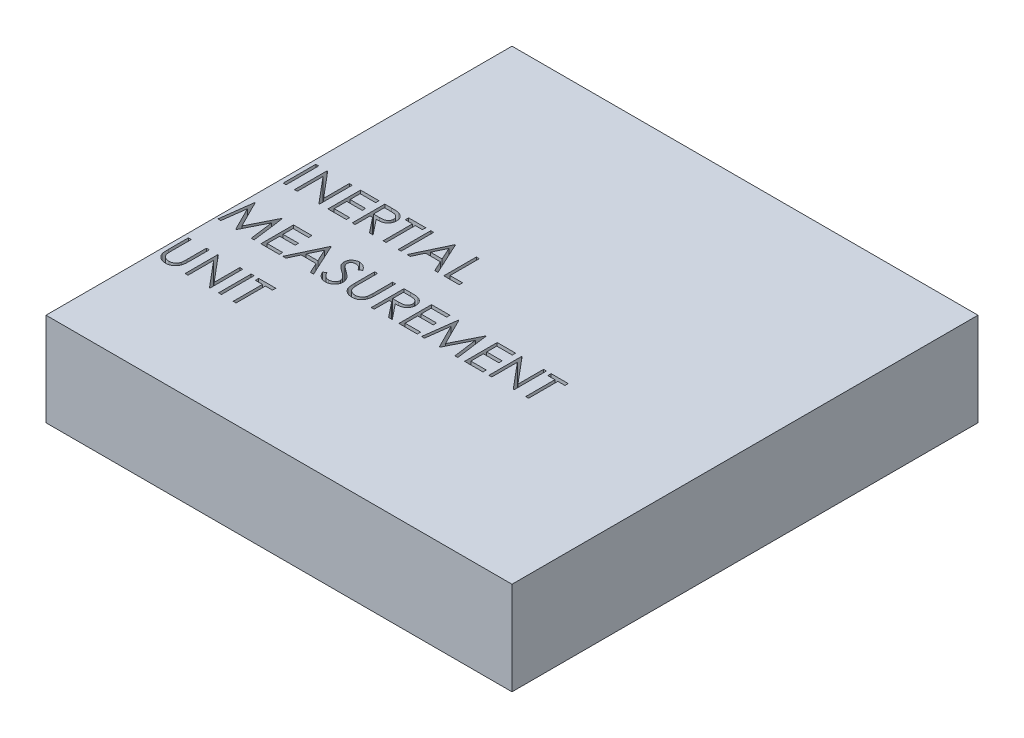
from build123d import *

# Parameters (mm, degrees)
SKETCH1_W           = 50
SKETCH1_H           = 50
BOSS_EXTRUDE1_DEPTH = 10
SKETCH2_W           = 0.314102564
SKETCH2_H           = 3.5
SKETCH2_W_2         = 0.314102565
CUT_EXTRUDE1_DEPTH  = 11


with BuildPart() as part:
    # Sketch1 → Boss-Extrude1 (new body)
    with BuildSketch(Plane(origin=(0, 0, 0), x_dir=(1, 0, 0), z_dir=(0, 1, 0))):
        with Locations((25, 25)):
            Rectangle(SKETCH1_W, SKETCH1_H)
    extrude(amount=BOSS_EXTRUDE1_DEPTH)

    # Sketch2 → Cut-Extrude1 (cut, through all)
    with BuildSketch(Plane(origin=(0, 10, 0), x_dir=(1, 0, 0), z_dir=(0, 1, 0))):
        with Locations((0.605769231, 26.75)):
            Rectangle(SKETCH2_W, SKETCH2_H)
        Polygon((1.66025641, 25), (1.66025641, 28.5), (1.726161859, 28.5), (4.038461538, 25.745292468), (4.038461538, 28.5), (4.352564103, 28.5), (4.352564103, 25), (4.281049679, 25), (1.974358974, 27.748397436), (1.974358974, 25), align=None)
        Polygon((5.25, 28.5), (7.224358974, 28.5), (7.224358974, 28.141025641), (5.564102564, 28.141025641), (5.564102564, 27.064102564), (7.224358974, 27.064102564), (7.224358974, 26.705128205), (5.564102564, 26.705128205), (5.564102564, 25.358974359), (7.224358974, 25.358974359), (7.224358974, 25), (5.25, 25), align=None)
        with BuildLine():
            Line((7.852564103, 28.5), (8.552984776, 28.5))
            add(Edge.make_bspline(
                [(8.552984776, 28.5), (8.599725904, 28.499844414), (8.689474049, 28.499545672), (8.818047319, 28.497879909), (8.934874416, 28.493105553), (9.039894255, 28.48899697), (9.13310491, 28.481505028), (9.214792201, 28.474344381), (9.284579898, 28.46497072), (9.32682575, 28.456265297), (9.345953526, 28.452323718)],
                knots=[0, 0, 0, 0, 0.000140226, 0.00026925, 0.000385712, 0.000490995, 0.000584507, 0.000666202, 0.000736998, 0.000795574, 0.000795574, 0.000795574, 0.000795574], degree=3))
            add(Edge.make_bspline(
                [(9.345953526, 28.452323718), (9.37156015, 28.445996953), (9.422227139, 28.433478389), (9.495177205, 28.407018788), (9.564691529, 28.376399163), (9.630481354, 28.340435443), (9.692217145, 28.298860663), (9.750535456, 28.252392541), (9.805700919, 28.201285335), (9.855482549, 28.144250494), (9.902421601, 28.084413984), (9.942010227, 28.019710227), (9.976136707, 27.9520487), (10.003307224, 27.880741282), (10.025185197, 27.80647951), (10.040611437, 27.728590713), (10.049862625, 27.647429738), (10.05080448, 27.59207183), (10.051282051, 27.564002404)],
                knots=[0, 0, 0, 0, 7.9081e-05, 0.000156475, 0.000232432, 0.000306798, 0.00038108, 0.000455429, 0.000530331, 0.000606314, 0.000682321, 0.000758201, 0.000833453, 0.000909362, 0.000986794, 0.001065445, 0.001147284, 0.001231465, 0.001231465, 0.001231465, 0.001231465], degree=3))
            add(Edge.make_bspline(
                [(10.051282051, 27.564002404), (10.049813053, 27.517367299), (10.046946657, 27.426370131), (10.020221554, 27.29430925), (9.976445034, 27.171119935), (9.916121745, 27.056957297), (9.839302269, 26.954046652), (9.746977478, 26.863656197), (9.639095867, 26.788016284), (9.538666551, 26.735563479), (9.449952351, 26.701970571), (9.376919038, 26.678334212), (9.297252061, 26.660072247), (9.211714726, 26.643712115), (9.119951071, 26.63136042), (9.022181031, 26.622313826), (8.91833488, 26.616659777), (8.84699581, 26.615817772), (8.810296474, 26.615384615)],
                knots=[0, 0, 0, 0, 0.000139777, 0.000272741, 0.000402249, 0.000530843, 0.000658588, 0.000786009, 0.000916741, 0.001052522, 0.001124656, 0.001201155, 0.001282612, 0.001369656, 0.001462366, 0.001560247, 0.001664165, 0.001774261, 0.001774261, 0.001774261, 0.001774261], degree=3))
            Line((8.810296474, 26.615384615), (10.096153846, 25))
            Line((10.096153846, 25), (9.707732372, 25))
            Line((9.707732372, 25), (8.421875, 26.615384615))
            Line((8.421875, 26.615384615), (8.166666667, 26.615384615))
            Line((8.166666667, 26.615384615), (8.166666667, 25))
            Line((8.166666667, 25), (7.852564103, 25))
            Line((7.852564103, 25), (7.852564103, 28.5))
        make_face()
        with BuildLine():
            Line((8.166666667, 28.141025641), (8.166666667, 26.974358974))
            Line((8.166666667, 26.974358974), (8.807491987, 26.969451122))
            add(Edge.make_bspline(
                [(8.807491987, 26.969451122), (8.837412026, 26.969437885), (8.895405583, 26.969412229), (8.979306248, 26.973406005), (9.05742636, 26.977949323), (9.129467112, 26.984898669), (9.195460687, 26.99385474), (9.2553741, 27.005057725), (9.309305152, 27.018109787), (9.372203691, 27.038311413), (9.442440222, 27.070317431), (9.518771682, 27.11688293), (9.58377402, 27.175452049), (9.638691882, 27.242425505), (9.682821314, 27.316061754), (9.713933368, 27.395478123), (9.73367581, 27.478669721), (9.736004356, 27.535847829), (9.737179487, 27.564703526)],
                knots=[0, 0, 0, 0, 8.9746e-05, 0.000173954, 0.000251933, 0.000324488, 0.000391021, 0.000451663, 0.000507268, 0.000557378, 0.000649639, 0.000738152, 0.000824558, 0.000910739, 0.000997194, 0.001080909, 0.00116578, 0.001252248, 0.001252248, 0.001252248, 0.001252248], degree=3))
            add(Edge.make_bspline(
                [(9.737179487, 27.564703526), (9.735977366, 27.592850099), (9.733595201, 27.648626338), (9.714146432, 27.730282248), (9.681257051, 27.807349198), (9.636934813, 27.879513683), (9.582935658, 27.945019419), (9.519617845, 28.001066572), (9.44871265, 28.047316037), (9.382441452, 28.076870418), (9.323207239, 28.094990271), (9.271777579, 28.107741435), (9.213666102, 28.117985904), (9.148590643, 28.126193964), (9.076829012, 28.133248909), (8.998018361, 28.138000687), (8.912681581, 28.140814551), (8.85353465, 28.14095364), (8.822916667, 28.141025641)],
                knots=[0, 0, 0, 0, 8.4371e-05, 0.000167192, 0.000250141, 0.000334794, 0.000420435, 0.000503871, 0.000587493, 0.000673488, 0.0007205, 0.000773215, 0.000832351, 0.0008974, 0.000969955, 0.001048634, 0.001134217, 0.001226067, 0.001226067, 0.001226067, 0.001226067], degree=3))
            Line((8.822916667, 28.141025641), (8.166666667, 28.141025641))
        make_face(mode=Mode.SUBTRACT)
        Polygon((10.41025641, 28.141025641), (10.41025641, 28.5), (12.25, 28.5), (12.25, 28.141025641), (11.487179487, 28.141025641), (11.487179487, 25), (11.173076923, 25), (11.173076923, 28.141025641), align=None)
        with Locations((12.94551282, 26.75)):
            Rectangle(SKETCH2_W_2, SKETCH2_H)
        Polygon((15.435897436, 28.5), (17.051282051, 25), (16.709835737, 25), (16.192407853, 26.121794872), (14.605769231, 26.121794872), (14.07431891, 25), (13.730769231, 25), (15.391025641, 28.5), align=None)
        Polygon((15.409955929, 27.817107372), (14.776842949, 26.480769231), (16.026943109, 26.480769231), align=None, mode=Mode.SUBTRACT)
        Polygon((17.679487179, 28.5), (17.993589744, 28.5), (17.993589744, 25.358974359), (19.33974359, 25.358974359), (19.33974359, 25), (17.679487179, 25), align=None)
        Polygon((0.269230769, 18.166666667), (0.731270032, 21.666666667), (0.776141827, 21.666666667), (2.221153846, 18.794871795), (3.661959135, 21.666666667), (3.706830929, 21.666666667), (4.173076923, 18.166666667), (3.858974359, 18.166666667), (3.522435897, 20.682992788), (2.259715545, 18.166666667), (2.188201122, 18.166666667), (0.919871795, 20.690705128), (0.585436699, 18.166666667), align=None)
        Polygon((4.891025641, 21.666666667), (6.865384615, 21.666666667), (6.865384615, 21.307692308), (5.205128205, 21.307692308), (5.205128205, 20.230769231), (6.865384615, 20.230769231), (6.865384615, 19.871794872), (5.205128205, 19.871794872), (5.205128205, 18.525641026), (6.865384615, 18.525641026), (6.865384615, 18.166666667), (4.891025641, 18.166666667), align=None)
        Polygon((8.929487179, 21.666666667), (10.544871795, 18.166666667), (10.203425481, 18.166666667), (9.685997596, 19.288461538), (8.099358974, 19.288461538), (7.567908654, 18.166666667), (7.224358974, 18.166666667), (8.884615385, 21.666666667), align=None)
        Polygon((8.903545673, 20.983774038), (8.270432692, 19.647435897), (9.520532853, 19.647435897), align=None, mode=Mode.SUBTRACT)
        with BuildLine():
            Line((10.814102564, 18.841846955), (11.109975962, 19.019230769))
            add(Edge.make_bspline(
                [(11.109975962, 19.019230769), (11.137494199, 18.973166384), (11.190218079, 18.8849088), (11.278169439, 18.76565076), (11.36930235, 18.664288603), (11.464291683, 18.581411996), (11.562557631, 18.516163109), (11.664741685, 18.469960877), (11.770499496, 18.441144902), (11.842473317, 18.437644815), (11.878405449, 18.435897436)],
                knots=[0, 0, 0, 0, 0.000160901, 0.00030828, 0.000443778, 0.00056903, 0.000685513, 0.000796284, 0.00090427, 0.001011928, 0.001011928, 0.001011928, 0.001011928], degree=3))
            add(Edge.make_bspline(
                [(11.878405449, 18.435897436), (11.909092309, 18.436752108), (11.969929082, 18.438446499), (12.059491325, 18.454727301), (12.146473128, 18.47973943), (12.229081765, 18.515560361), (12.30617738, 18.558898847), (12.373784075, 18.611245024), (12.432230188, 18.66985123), (12.480039303, 18.735233885), (12.516719338, 18.805551033), (12.544911407, 18.877726985), (12.56055648, 18.952895553), (12.562913234, 19.003506016), (12.564102564, 19.029046474)],
                knots=[0, 0, 0, 0, 9.1978e-05, 0.000182347, 0.000272202, 0.000362975, 0.000451852, 0.000536835, 0.000618639, 0.000699414, 0.000778765, 0.000855983, 0.0009312, 0.001007828, 0.001007828, 0.001007828, 0.001007828], degree=3))
            add(Edge.make_bspline(
                [(12.564102564, 19.029046474), (12.562628253, 19.058187324), (12.559631195, 19.117426413), (12.534299715, 19.204826066), (12.494450468, 19.291318636), (12.457687825, 19.344819902), (12.438601763, 19.372596154)],
                knots=[0, 0, 0, 0, 8.7281e-05, 0.000177429, 0.000270909, 0.000371844, 0.000371844, 0.000371844, 0.000371844], degree=3))
            add(Edge.make_bspline(
                [(12.438601763, 19.372596154), (12.422931149, 19.392642977), (12.390032654, 19.434728776), (12.333475142, 19.497374011), (12.267109027, 19.56199243), (12.193205473, 19.631051487), (12.109072384, 19.701339284), (12.017344869, 19.776207562), (11.91568101, 19.852809139), (11.844381514, 19.904181705), (11.807592147, 19.930689103)],
                knots=[0, 0, 0, 0, 7.6319e-05, 0.000160223, 0.000252933, 0.000354147, 0.000463581, 0.000581729, 0.000709336, 0.000845369, 0.000845369, 0.000845369, 0.000845369], degree=3))
            add(Edge.make_bspline(
                [(11.807592147, 19.930689103), (11.770768151, 19.95691769), (11.700363475, 20.007064752), (11.601904892, 20.081489036), (11.513860429, 20.149532906), (11.436621413, 20.211836918), (11.370221816, 20.268409523), (11.314138405, 20.318707462), (11.269799848, 20.364091023), (11.245144267, 20.393532365), (11.234074519, 20.406750801)],
                knots=[0, 0, 0, 0, 0.000135623, 0.000259301, 0.000370234, 0.000469439, 0.00055697, 0.000631911, 0.000695377, 0.00074709, 0.00074709, 0.00074709, 0.00074709], degree=3))
            add(Edge.make_bspline(
                [(11.234074519, 20.406750801), (11.218601974, 20.427351838), (11.188173137, 20.467866542), (11.148007132, 20.5311914), (11.113867969, 20.596014665), (11.087105637, 20.66251053), (11.064569418, 20.729745459), (11.049411487, 20.798596704), (11.03992009, 20.868755323), (11.038948104, 20.915968823), (11.038461538, 20.939603365)],
                knots=[0, 0, 0, 0, 7.727e-05, 0.000151962, 0.000224716, 0.000296717, 0.00036678, 0.0004372, 0.000507902, 0.000578771, 0.000578771, 0.000578771, 0.000578771], degree=3))
            add(Edge.make_bspline(
                [(11.038461538, 20.939603365), (11.039766747, 20.97663314), (11.042349268, 21.049901204), (11.064189785, 21.156932034), (11.098662678, 21.259118451), (11.146957566, 21.355448785), (11.209214919, 21.443414766), (11.281260894, 21.524028253), (11.36707238, 21.591796835), (11.461225003, 21.651008894), (11.564281375, 21.697354819), (11.672272279, 21.732315799), (11.785369351, 21.752125057), (11.861972485, 21.754967822), (11.900841346, 21.756410256)],
                knots=[0, 0, 0, 0, 0.000110999, 0.000219625, 0.000326272, 0.00043382, 0.000541574, 0.000648775, 0.000756959, 0.000868438, 0.000981703, 0.00109501, 0.001208203, 0.0013248, 0.0013248, 0.0013248, 0.0013248], degree=3))
            add(Edge.make_bspline(
                [(11.900841346, 21.756410256), (11.942085446, 21.754987705), (12.024106798, 21.752158704), (12.144756014, 21.727561172), (12.26091673, 21.686860501), (12.354359995, 21.640671843), (12.427492756, 21.594540427), (12.483265489, 21.552520603), (12.53978294, 21.504145494), (12.597500995, 21.449286248), (12.655441654, 21.387439497), (12.714465106, 21.319028808), (12.774709375, 21.244472252), (12.813465235, 21.191247751), (12.833333333, 21.16396234)],
                knots=[0, 0, 0, 0, 0.000123638, 0.000245877, 0.000367608, 0.000492088, 0.000557638, 0.000626769, 0.000701372, 0.00078072, 0.000865532, 0.000955497, 0.001051745, 0.001152989, 0.001152989, 0.001152989, 0.001152989], degree=3))
            Line((12.833333333, 21.16396234), (12.549379006, 20.948717949))
            add(Edge.make_bspline(
                [(12.549379006, 20.948717949), (12.532233074, 20.970806639), (12.499214017, 21.013344292), (12.44908453, 21.072915608), (12.401835882, 21.127332088), (12.355285482, 21.174597216), (12.311891851, 21.217299349), (12.269774809, 21.253859106), (12.229540457, 21.284634701), (12.178823547, 21.317478261), (12.115105828, 21.350034765), (12.035121292, 21.377583843), (11.951535017, 21.394138905), (11.894605386, 21.396327792), (11.865785256, 21.397435897)],
                knots=[0, 0, 0, 0, 8.3877e-05, 0.000161528, 0.000233552, 0.000299993, 0.000360485, 0.000416152, 0.000467195, 0.000512312, 0.000597287, 0.000681099, 0.000765389, 0.000851809, 0.000851809, 0.000851809, 0.000851809], degree=3))
            add(Edge.make_bspline(
                [(11.865785256, 21.397435897), (11.829628734, 21.396224197), (11.759904287, 21.393887548), (11.66091405, 21.368367563), (11.571820125, 21.328185703), (11.49526756, 21.271870725), (11.431530583, 21.205149732), (11.385425125, 21.128370877), (11.35767496, 21.043588474), (11.35428868, 20.984446818), (11.352564103, 20.954326923)],
                knots=[0, 0, 0, 0, 0.000108248, 0.000208746, 0.00030443, 0.000399793, 0.000492054, 0.00057947, 0.000666386, 0.000756591, 0.000756591, 0.000756591, 0.000756591], degree=3))
            add(Edge.make_bspline(
                [(11.352564103, 20.954326923), (11.352957229, 20.935575445), (11.353744125, 20.898041825), (11.364718923, 20.842590403), (11.378818252, 20.787279064), (11.401160884, 20.732356481), (11.432006187, 20.676862122), (11.472511363, 20.619840384), (11.523524675, 20.560788676), (11.562601688, 20.522381302), (11.583233173, 20.502103365)],
                knots=[0, 0, 0, 0, 5.616e-05, 0.000112411, 0.000169046, 0.000227244, 0.000289691, 0.000359134, 0.000436702, 0.000523463, 0.000523463, 0.000523463, 0.000523463], degree=3))
            add(Edge.make_bspline(
                [(11.583233173, 20.502103365), (11.590894545, 20.49526634), (11.609096213, 20.479023131), (11.642372138, 20.452430851), (11.686314937, 20.419628078), (11.739777138, 20.379040762), (11.803744499, 20.3319593), (11.878224056, 20.278985688), (11.962385588, 20.218400229), (12.022107504, 20.176042688), (12.053685897, 20.153645833)],
                knots=[0, 0, 0, 0, 3.0802e-05, 7.3177e-05, 0.000127725, 0.000195314, 0.000274544, 0.000365991, 0.000469501, 0.000585644, 0.000585644, 0.000585644, 0.000585644], degree=3))
            add(Edge.make_bspline(
                [(12.053685897, 20.153645833), (12.091671811, 20.126004474), (12.165226267, 20.072480812), (12.269883847, 19.992065132), (12.364777655, 19.913417363), (12.450240859, 19.837039756), (12.527117767, 19.763511663), (12.594555488, 19.691948483), (12.653241168, 19.62286291), (12.716420387, 19.534290335), (12.780978206, 19.42550925), (12.836419714, 19.292231012), (12.871378061, 19.158434691), (12.875949576, 19.068507855), (12.878205128, 19.024138622)],
                knots=[0, 0, 0, 0, 0.000140932, 0.000272896, 0.000395881, 0.000510584, 0.000616697, 0.000714904, 0.000805482, 0.000888372, 0.001041088, 0.001183793, 0.001320341, 0.001453327, 0.001453327, 0.001453327, 0.001453327], degree=3))
            add(Edge.make_bspline(
                [(12.878205128, 19.024138622), (12.87754799, 18.992760257), (12.876246475, 18.930612873), (12.861285561, 18.839357796), (12.839365896, 18.750726927), (12.806328662, 18.665815814), (12.766005504, 18.583071051), (12.714839256, 18.504663151), (12.655531571, 18.428856752), (12.587497806, 18.357673261), (12.513051904, 18.292327065), (12.434368209, 18.234198004), (12.351317936, 18.18572968), (12.26435162, 18.146178838), (12.173449283, 18.115245321), (12.078641499, 18.092832452), (11.979771988, 18.079076741), (11.912571506, 18.077648979), (11.878405449, 18.076923077)],
                knots=[0, 0, 0, 0, 9.4044e-05, 0.000186263, 0.000276729, 0.000367488, 0.000459046, 0.000552398, 0.000647774, 0.000747454, 0.000847311, 0.000944634, 0.001040472, 0.001135227, 0.001230788, 0.001328063, 0.00142712, 0.00152957, 0.00152957, 0.00152957, 0.00152957], degree=3))
            add(Edge.make_bspline(
                [(11.878405449, 18.076923077), (11.851970106, 18.077434259), (11.799432346, 18.078450184), (11.721722864, 18.087431464), (11.645583275, 18.100138568), (11.571968993, 18.120312638), (11.499931581, 18.144789615), (11.429784346, 18.174927948), (11.361493293, 18.211045149), (11.29467571, 18.252340174), (11.229501535, 18.300397918), (11.166582067, 18.356371415), (11.103852882, 18.41871692), (11.043165485, 18.489127483), (10.983292341, 18.566465566), (10.925413931, 18.651454749), (10.868332214, 18.743632103), (10.832516746, 18.808497189), (10.814102564, 18.841846955)],
                knots=[0, 0, 0, 0, 7.9276e-05, 0.000157554, 0.000234438, 0.000310629, 0.000386236, 0.000462555, 0.000539392, 0.000617798, 0.000698008, 0.000781971, 0.000870217, 0.00096315, 0.001060616, 0.001163492, 0.001271478, 0.00138575, 0.00138575, 0.00138575, 0.00138575], degree=3))
        make_face()
        with BuildLine():
            Line((13.596153846, 21.666666667), (13.91025641, 21.666666667))
            Line((13.91025641, 21.666666667), (13.91025641, 19.569611378))
            add(Edge.make_bspline(
                [(13.91025641, 19.569611378), (13.910209666, 19.539930642), (13.910120962, 19.483606332), (13.910713475, 19.403438031), (13.912372844, 19.332165572), (13.913419003, 19.269514224), (13.915746337, 19.215771477), (13.917644384, 19.170646166), (13.920084941, 19.134351964), (13.923018058, 19.113171038), (13.924278846, 19.104066506)],
                knots=[0, 0, 0, 0, 8.9042e-05, 0.000168973, 0.000240502, 0.000302917, 0.000356945, 0.000401866, 0.000438432, 0.000465999, 0.000465999, 0.000465999, 0.000465999], degree=3))
            add(Edge.make_bspline(
                [(13.924278846, 19.104066506), (13.929456305, 19.071219743), (13.939519491, 19.007377014), (13.965165869, 18.916468732), (14.00098337, 18.834537274), (14.043426413, 18.759025983), (14.099359024, 18.692036623), (14.166362559, 18.63032497), (14.247540328, 18.576353165), (14.337800934, 18.527002353), (14.435086171, 18.487337271), (14.534497437, 18.457343907), (14.634540417, 18.439065007), (14.701516582, 18.436948468), (14.734775641, 18.435897436)],
                knots=[0, 0, 0, 0, 9.971e-05, 0.000193801, 0.000282365, 0.000367504, 0.000452699, 0.000543015, 0.000639862, 0.000744331, 0.000851226, 0.000954377, 0.001055468, 0.001155185, 0.001155185, 0.001155185, 0.001155185], degree=3))
            add(Edge.make_bspline(
                [(14.734775641, 18.435897436), (14.763329381, 18.436971286), (14.820271943, 18.439112784), (14.904878374, 18.452374215), (14.987278483, 18.476274781), (15.067879163, 18.50711454), (15.143430147, 18.547862131), (15.213973589, 18.59493297), (15.276937523, 18.650143846), (15.334395521, 18.711244191), (15.384430457, 18.780183991), (15.427801599, 18.855462129), (15.463327528, 18.938211476), (15.480871053, 18.996365898), (15.489883814, 19.026241987)],
                knots=[0, 0, 0, 0, 8.5678e-05, 0.00017086, 0.000256092, 0.000342674, 0.000429242, 0.000513055, 0.000596556, 0.000679898, 0.000764179, 0.00085149, 0.000940054, 0.001033621, 0.001033621, 0.001033621, 0.001033621], degree=3))
            add(Edge.make_bspline(
                [(15.489883814, 19.026241987), (15.492883939, 19.038590562), (15.499569428, 19.066108162), (15.505816473, 19.112629452), (15.512322998, 19.167518816), (15.516837568, 19.231170629), (15.521238788, 19.303371602), (15.523871861, 19.384497859), (15.525088894, 19.47425482), (15.525451574, 19.536891982), (15.525641026, 19.569611378)],
                knots=[0, 0, 0, 0, 3.81e-05, 8.4902e-05, 0.000140649, 0.000203941, 0.000276279, 0.000357657, 0.000447412, 0.000545571, 0.000545571, 0.000545571, 0.000545571], degree=3))
            Line((15.525641026, 19.569611378), (15.525641026, 21.666666667))
            Line((15.525641026, 21.666666667), (15.83974359, 21.666666667))
            Line((15.83974359, 21.666666667), (15.83974359, 19.552784455))
            add(Edge.make_bspline(
                [(15.83974359, 19.552784455), (15.839489469, 19.514686076), (15.838993538, 19.440334773), (15.834692961, 19.331383414), (15.827835962, 19.228030433), (15.818147874, 19.130261936), (15.80531087, 19.038427777), (15.79103565, 18.951723009), (15.772856117, 18.870770016), (15.751622716, 18.794937599), (15.727349168, 18.722752085), (15.695908019, 18.654243471), (15.660483519, 18.587329071), (15.618468867, 18.523020962), (15.571257484, 18.461034409), (15.517805803, 18.401745334), (15.459881642, 18.344206288), (15.396522083, 18.289893222), (15.328771557, 18.240084545), (15.2568316, 18.196286774), (15.18125483, 18.159263156), (15.102237704, 18.128787232), (15.019746501, 18.105872632), (14.933779141, 18.088797477), (14.844139948, 18.079095179), (14.783175292, 18.077653249), (14.752303686, 18.076923077)],
                knots=[0, 0, 0, 0, 0.000114291, 0.000223047, 0.000327049, 0.000424998, 0.000517708, 0.000605194, 0.000688542, 0.000766455, 0.0008414, 0.000916717, 0.000992315, 0.001068354, 0.001146882, 0.001225836, 0.001307639, 0.001391671, 0.001475952, 0.001559641, 0.001643989, 0.001728103, 0.001813335, 0.001900511, 0.00199079, 0.002083404, 0.002083404, 0.002083404, 0.002083404], degree=3))
            add(Edge.make_bspline(
                [(14.752303686, 18.076923077), (14.718634583, 18.077707842), (14.652575924, 18.079247549), (14.555237857, 18.088070299), (14.461923661, 18.104688693), (14.371647784, 18.125848637), (14.285639287, 18.155032374), (14.202745842, 18.189130499), (14.124387161, 18.231007759), (14.049292033, 18.277601152), (13.979467276, 18.330025791), (13.915369873, 18.387165965), (13.856894003, 18.448106342), (13.805025306, 18.513506708), (13.758904422, 18.582858415), (13.719174208, 18.656357655), (13.685060964, 18.733975971), (13.667454397, 18.787929171), (13.658553686, 18.815204327)],
                knots=[0, 0, 0, 0, 0.000101022, 0.000198206, 0.000292839, 0.000385177, 0.00047608, 0.000565014, 0.000653769, 0.000742283, 0.000829923, 0.000915339, 0.000999643, 0.001082971, 0.00116542, 0.001249186, 0.001333332, 0.001419362, 0.001419362, 0.001419362, 0.001419362], degree=3))
            add(Edge.make_bspline(
                [(13.658553686, 18.815204327), (13.653376528, 18.833836901), (13.642147156, 18.87425137), (13.630121859, 18.941137859), (13.620012777, 19.018152777), (13.610507219, 19.105301395), (13.604898261, 19.202651261), (13.599980822, 19.310160177), (13.596119203, 19.427958139), (13.596141976, 19.510012655), (13.596153846, 19.552784455)],
                knots=[0, 0, 0, 0, 5.799e-05, 0.000125782, 0.000203619, 0.000291034, 0.000388694, 0.000496078, 0.000613919, 0.000742226, 0.000742226, 0.000742226, 0.000742226], degree=3))
            Line((13.596153846, 19.552784455), (13.596153846, 21.666666667))
        make_face()
        with BuildLine():
            Line((16.737179487, 21.666666667), (17.43760016, 21.666666667))
            add(Edge.make_bspline(
                [(17.43760016, 21.666666667), (17.484341289, 21.666511081), (17.574089433, 21.666212338), (17.702662704, 21.664546575), (17.819489801, 21.65977222), (17.92450964, 21.655663636), (18.017720295, 21.648171695), (18.099407586, 21.641011048), (18.169195283, 21.631637387), (18.211441134, 21.622931964), (18.23056891, 21.618990385)],
                knots=[0, 0, 0, 0, 0.000140226, 0.00026925, 0.000385712, 0.000490995, 0.000584507, 0.000666202, 0.000736998, 0.000795574, 0.000795574, 0.000795574, 0.000795574], degree=3))
            add(Edge.make_bspline(
                [(18.23056891, 21.618990385), (18.256175534, 21.612663619), (18.306842524, 21.600145056), (18.37979259, 21.573685455), (18.449306914, 21.54306583), (18.515096738, 21.50710211), (18.576832529, 21.46552733), (18.63515084, 21.419059208), (18.690316304, 21.367952002), (18.740097934, 21.31091716), (18.787036985, 21.251080651), (18.826625612, 21.186376894), (18.860752092, 21.118715366), (18.887922609, 21.047407949), (18.909800582, 20.973146177), (18.925226821, 20.89525738), (18.934478009, 20.814096405), (18.935419865, 20.758738496), (18.935897436, 20.730669071)],
                knots=[0, 0, 0, 0, 7.9081e-05, 0.000156475, 0.000232432, 0.000306798, 0.00038108, 0.000455429, 0.000530331, 0.000606314, 0.000682321, 0.000758201, 0.000833453, 0.000909362, 0.000986794, 0.001065445, 0.001147284, 0.001231465, 0.001231465, 0.001231465, 0.001231465], degree=3))
            add(Edge.make_bspline(
                [(18.935897436, 20.730669071), (18.934428438, 20.684033966), (18.931562042, 20.593036798), (18.904836938, 20.460975917), (18.861060419, 20.337786602), (18.80073713, 20.223623964), (18.723917654, 20.120713319), (18.631592863, 20.030322863), (18.523711251, 19.954682951), (18.423281935, 19.902230146), (18.334567736, 19.868637237), (18.261534423, 19.845000879), (18.181867445, 19.826738913), (18.096330111, 19.810378782), (18.004566455, 19.798027087), (17.906796416, 19.788980493), (17.802950264, 19.783326444), (17.731611195, 19.782484439), (17.694911859, 19.782051282)],
                knots=[0, 0, 0, 0, 0.000139777, 0.000272741, 0.000402249, 0.000530843, 0.000658588, 0.000786009, 0.000916741, 0.001052522, 0.001124656, 0.001201155, 0.001282612, 0.001369656, 0.001462366, 0.001560247, 0.001664165, 0.001774261, 0.001774261, 0.001774261, 0.001774261], degree=3))
            Line((17.694911859, 19.782051282), (18.980769231, 18.166666667))
            Line((18.980769231, 18.166666667), (18.592347756, 18.166666667))
            Line((18.592347756, 18.166666667), (17.306490385, 19.782051282))
            Line((17.306490385, 19.782051282), (17.051282051, 19.782051282))
            Line((17.051282051, 19.782051282), (17.051282051, 18.166666667))
            Line((17.051282051, 18.166666667), (16.737179487, 18.166666667))
            Line((16.737179487, 18.166666667), (16.737179487, 21.666666667))
        make_face()
        with BuildLine():
            Line((17.051282051, 21.307692308), (17.051282051, 20.141025641))
            Line((17.051282051, 20.141025641), (17.692107372, 20.136117788))
            add(Edge.make_bspline(
                [(17.692107372, 20.136117788), (17.722027411, 20.136104552), (17.780020968, 20.136078895), (17.863921633, 20.140072672), (17.942041744, 20.14461599), (18.014082497, 20.151565335), (18.080076072, 20.160521407), (18.139989485, 20.171724391), (18.193920537, 20.184776454), (18.256819075, 20.20497808), (18.327055607, 20.236984098), (18.403387067, 20.283549597), (18.468389404, 20.342118716), (18.523307267, 20.409092172), (18.567436698, 20.482728421), (18.598548752, 20.56214479), (18.618291195, 20.645336388), (18.62061974, 20.702514496), (18.621794872, 20.731370192)],
                knots=[0, 0, 0, 0, 8.9746e-05, 0.000173954, 0.000251933, 0.000324488, 0.000391021, 0.000451663, 0.000507268, 0.000557378, 0.000649639, 0.000738152, 0.000824558, 0.000910739, 0.000997194, 0.001080909, 0.00116578, 0.001252248, 0.001252248, 0.001252248, 0.001252248], degree=3))
            add(Edge.make_bspline(
                [(18.621794872, 20.731370192), (18.620592751, 20.759516766), (18.618210585, 20.815293005), (18.598761817, 20.896948915), (18.565872435, 20.974015865), (18.521550198, 21.04618035), (18.467551043, 21.111686086), (18.40423323, 21.167733239), (18.333328035, 21.213982704), (18.267056836, 21.243537084), (18.207822624, 21.261656937), (18.156392964, 21.274408101), (18.098281486, 21.28465257), (18.033206028, 21.292860631), (17.961444397, 21.299915575), (17.882633746, 21.304667354), (17.797296965, 21.307481218), (17.738150034, 21.307620307), (17.707532051, 21.307692308)],
                knots=[0, 0, 0, 0, 8.4371e-05, 0.000167192, 0.000250141, 0.000334794, 0.000420435, 0.000503871, 0.000587493, 0.000673488, 0.0007205, 0.000773215, 0.000832351, 0.0008974, 0.000969955, 0.001048634, 0.001134217, 0.001226067, 0.001226067, 0.001226067, 0.001226067], degree=3))
            Line((17.707532051, 21.307692308), (17.051282051, 21.307692308))
        make_face(mode=Mode.SUBTRACT)
        Polygon((19.698717949, 21.666666667), (21.673076923, 21.666666667), (21.673076923, 21.307692308), (20.012820513, 21.307692308), (20.012820513, 20.230769231), (21.673076923, 20.230769231), (21.673076923, 19.871794872), (20.012820513, 19.871794872), (20.012820513, 18.525641026), (21.673076923, 18.525641026), (21.673076923, 18.166666667), (19.698717949, 18.166666667), align=None)
        Polygon((22.121794872, 18.166666667), (22.583834135, 21.666666667), (22.628705929, 21.666666667), (24.073717949, 18.794871795), (25.514523237, 21.666666667), (25.559395032, 21.666666667), (26.025641026, 18.166666667), (25.711538462, 18.166666667), (25.375, 20.682992788), (24.112279647, 18.166666667), (24.040765224, 18.166666667), (22.772435897, 20.690705128), (22.438000801, 18.166666667), align=None)
        Polygon((26.743589744, 21.666666667), (28.717948718, 21.666666667), (28.717948718, 21.307692308), (27.057692308, 21.307692308), (27.057692308, 20.230769231), (28.717948718, 20.230769231), (28.717948718, 19.871794872), (27.057692308, 19.871794872), (27.057692308, 18.525641026), (28.717948718, 18.525641026), (28.717948718, 18.166666667), (26.743589744, 18.166666667), align=None)
        Polygon((29.346153846, 18.166666667), (29.346153846, 21.666666667), (29.412059295, 21.666666667), (31.724358974, 18.911959135), (31.724358974, 21.666666667), (32.038461538, 21.666666667), (32.038461538, 18.166666667), (31.966947115, 18.166666667), (29.66025641, 20.915064103), (29.66025641, 18.166666667), align=None)
        Polygon((32.532051282, 21.307692308), (32.532051282, 21.666666667), (34.371794872, 21.666666667), (34.371794872, 21.307692308), (33.608974359, 21.307692308), (33.608974359, 18.166666667), (33.294871795, 18.166666667), (33.294871795, 21.307692308), align=None)
        with BuildLine():
            Line((0.448717949, 14.833333333), (0.762820513, 14.833333333))
            Line((0.762820513, 14.833333333), (0.762820513, 12.736278045))
            add(Edge.make_bspline(
                [(0.762820513, 12.736278045), (0.762773769, 12.706597309), (0.762685064, 12.650272998), (0.763277578, 12.570104698), (0.764936946, 12.498832239), (0.765983106, 12.436180891), (0.768310439, 12.382438144), (0.770208486, 12.337312833), (0.772649043, 12.30101863), (0.775582161, 12.279837704), (0.776842949, 12.270733173)],
                knots=[0, 0, 0, 0, 8.9042e-05, 0.000168973, 0.000240502, 0.000302917, 0.000356945, 0.000401866, 0.000438432, 0.000465999, 0.000465999, 0.000465999, 0.000465999], degree=3))
            add(Edge.make_bspline(
                [(0.776842949, 12.270733173), (0.782020408, 12.23788641), (0.792083594, 12.174043681), (0.817729972, 12.083135399), (0.853547473, 12.00120394), (0.895990515, 11.925692649), (0.951923127, 11.858703289), (1.018926662, 11.796991637), (1.100104431, 11.743019832), (1.190365036, 11.69366902), (1.287650274, 11.654003938), (1.38706154, 11.624010573), (1.487104519, 11.605731674), (1.554080684, 11.603615135), (1.587339744, 11.602564103)],
                knots=[0, 0, 0, 0, 9.971e-05, 0.000193801, 0.000282365, 0.000367504, 0.000452699, 0.000543015, 0.000639862, 0.000744331, 0.000851226, 0.000954377, 0.001055468, 0.001155185, 0.001155185, 0.001155185, 0.001155185], degree=3))
            add(Edge.make_bspline(
                [(1.587339744, 11.602564103), (1.615893484, 11.603637953), (1.672836046, 11.605779451), (1.757442477, 11.619040882), (1.839842585, 11.642941448), (1.920443265, 11.673781206), (1.99599425, 11.714528797), (2.066537692, 11.761599637), (2.129501626, 11.816810513), (2.186959624, 11.877910857), (2.236994559, 11.946850657), (2.280365701, 12.022128795), (2.315891631, 12.104878142), (2.333435156, 12.163032565), (2.342447917, 12.192908654)],
                knots=[0, 0, 0, 0, 8.5678e-05, 0.00017086, 0.000256092, 0.000342674, 0.000429242, 0.000513055, 0.000596556, 0.000679898, 0.000764179, 0.00085149, 0.000940054, 0.001033621, 0.001033621, 0.001033621, 0.001033621], degree=3))
            add(Edge.make_bspline(
                [(2.342447917, 12.192908654), (2.345448042, 12.205257228), (2.35213353, 12.232774828), (2.358380575, 12.279296119), (2.364887101, 12.334185483), (2.369401671, 12.397837296), (2.373802891, 12.470038268), (2.376435964, 12.551164526), (2.377652997, 12.640921487), (2.378015677, 12.703558648), (2.378205128, 12.736278045)],
                knots=[0, 0, 0, 0, 3.81e-05, 8.4902e-05, 0.000140649, 0.000203941, 0.000276279, 0.000357657, 0.000447412, 0.000545571, 0.000545571, 0.000545571, 0.000545571], degree=3))
            Line((2.378205128, 12.736278045), (2.378205128, 14.833333333))
            Line((2.378205128, 14.833333333), (2.692307692, 14.833333333))
            Line((2.692307692, 14.833333333), (2.692307692, 12.719451122))
            add(Edge.make_bspline(
                [(2.692307692, 12.719451122), (2.692053572, 12.681352743), (2.691557641, 12.60700144), (2.687257064, 12.498050081), (2.680400064, 12.3946971), (2.670711976, 12.296928603), (2.657874973, 12.205094444), (2.643599753, 12.118389676), (2.625420219, 12.037436683), (2.604186818, 11.961604265), (2.57991327, 11.889418752), (2.548472122, 11.820910137), (2.513047622, 11.753995738), (2.471032969, 11.689687629), (2.423821586, 11.627701076), (2.370369906, 11.568412001), (2.312445745, 11.510872954), (2.249086185, 11.456559888), (2.18133566, 11.406751211), (2.109395702, 11.36295344), (2.033818933, 11.325929823), (1.954801806, 11.295453898), (1.872310604, 11.272539299), (1.786343244, 11.255464143), (1.69670405, 11.245761846), (1.635739394, 11.244319916), (1.604867788, 11.243589744)],
                knots=[0, 0, 0, 0, 0.000114291, 0.000223047, 0.000327049, 0.000424998, 0.000517708, 0.000605194, 0.000688542, 0.000766455, 0.0008414, 0.000916717, 0.000992315, 0.001068354, 0.001146882, 0.001225836, 0.001307639, 0.001391671, 0.001475952, 0.001559641, 0.001643989, 0.001728103, 0.001813335, 0.001900511, 0.00199079, 0.002083404, 0.002083404, 0.002083404, 0.002083404], degree=3))
            add(Edge.make_bspline(
                [(1.604867788, 11.243589744), (1.571198686, 11.244374509), (1.505140027, 11.245914215), (1.40780196, 11.254736966), (1.314487763, 11.27135536), (1.224211886, 11.292515304), (1.138203389, 11.321699041), (1.055309945, 11.355797166), (0.976951264, 11.397674426), (0.901856135, 11.444267819), (0.832031379, 11.496692457), (0.767933976, 11.553832631), (0.709458105, 11.614773009), (0.657589409, 11.680173374), (0.611468524, 11.749525081), (0.571738311, 11.823024321), (0.537625067, 11.900642637), (0.5200185, 11.954595838), (0.511117788, 11.981870994)],
                knots=[0, 0, 0, 0, 0.000101022, 0.000198206, 0.000292839, 0.000385177, 0.00047608, 0.000565014, 0.000653769, 0.000742283, 0.000829923, 0.000915339, 0.000999643, 0.001082971, 0.00116542, 0.001249186, 0.001333332, 0.001419362, 0.001419362, 0.001419362, 0.001419362], degree=3))
            add(Edge.make_bspline(
                [(0.511117788, 11.981870994), (0.50594063, 12.000503568), (0.494711259, 12.040918037), (0.482685961, 12.107804526), (0.47257688, 12.184819443), (0.463071321, 12.271968062), (0.457462363, 12.369317928), (0.452544925, 12.476826844), (0.448683306, 12.594624806), (0.448706078, 12.676679321), (0.448717949, 12.719451122)],
                knots=[0, 0, 0, 0, 5.799e-05, 0.000125782, 0.000203619, 0.000291034, 0.000388694, 0.000496078, 0.000613919, 0.000742226, 0.000742226, 0.000742226, 0.000742226], degree=3))
            Line((0.448717949, 12.719451122), (0.448717949, 14.833333333))
        make_face()
        Polygon((3.58974359, 11.333333333), (3.58974359, 14.833333333), (3.655649038, 14.833333333), (5.967948718, 12.078625801), (5.967948718, 14.833333333), (6.282051282, 14.833333333), (6.282051282, 11.333333333), (6.210536859, 11.333333333), (3.903846154, 14.081730769), (3.903846154, 11.333333333), align=None)
        with Locations((7.336538461, 13.083333333)):
            Rectangle(SKETCH2_W_2, SKETCH2_H)
        Polygon((7.987179487, 14.474358974), (7.987179487, 14.833333333), (9.826923077, 14.833333333), (9.826923077, 14.474358974), (9.064102564, 14.474358974), (9.064102564, 11.333333333), (8.75, 11.333333333), (8.75, 14.474358974), align=None)
    extrude(amount=-CUT_EXTRUDE1_DEPTH, mode=Mode.SUBTRACT)


solid = part.part
